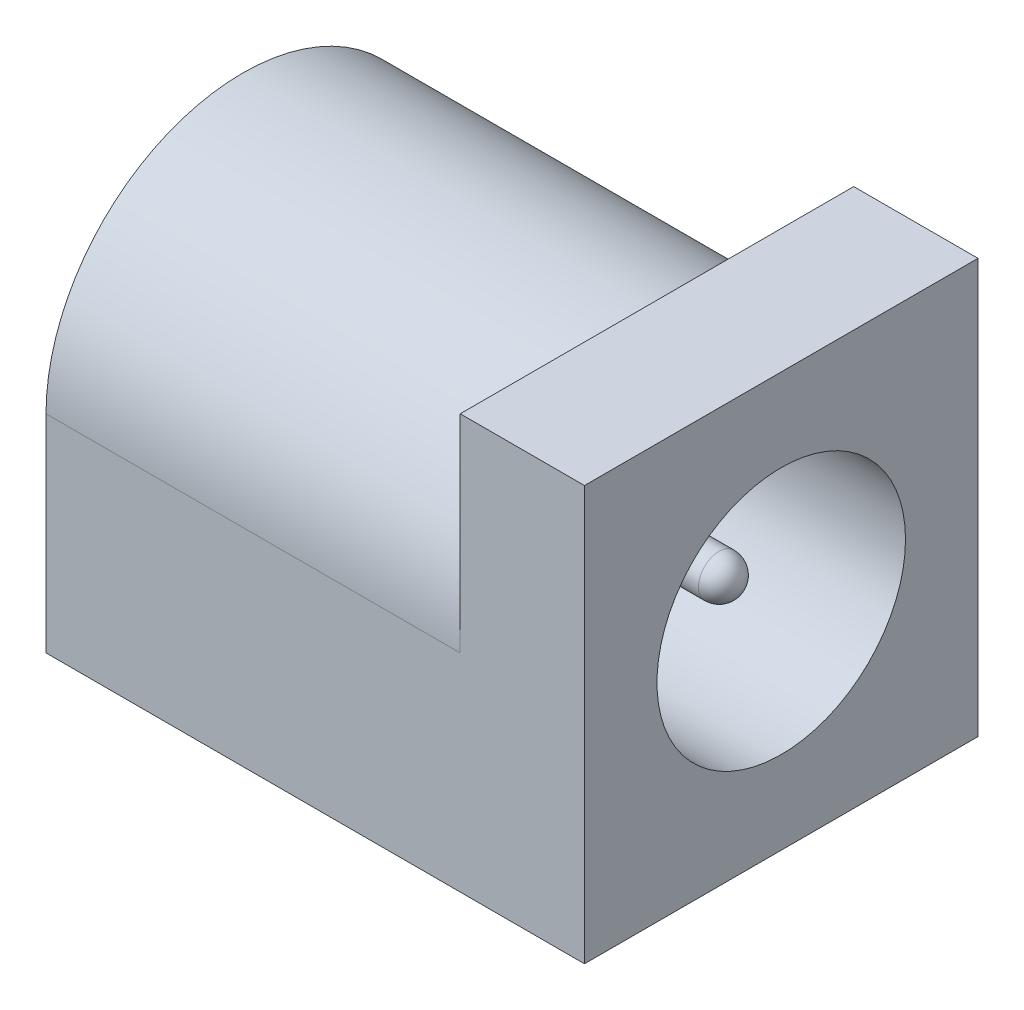
from build123d import *

# Parameters (mm, degrees)
BOSS_EXTRUDE1_DEPTH = 10
SKETCH2_W           = 9.5
SKETCH2_H           = 10
BOSS_EXTRUDE2_DEPTH = 3
SKETCH3_R           = 3
CUT_EXTRUDE1_DEPTH  = 12
SKETCH4_R           = 0.5
BOSS_EXTRUDE3_DEPTH = 11
FILLET1_R           = 0.5


with BuildPart() as part:
    # Sketch1 → Boss-Extrude1 (new body)
    with BuildSketch(Plane(origin=(0, 0, 0), x_dir=(0, 0, -1), z_dir=(1, 0, 0))):
        with BuildLine():
            Line((-4.75, -2.5), (4.75, -2.5))
            Line((4.75, -2.5), (4.75, 2.5))
            ThreePointArc((4.75, 2.5), (0, 7.25), (-4.75, 2.5))
            Line((-4.75, 2.5), (-4.75, -2.5))
        make_face()
    extrude(amount=BOSS_EXTRUDE1_DEPTH)

    # Sketch2 → Boss-Extrude2 (add)
    with BuildSketch(Plane(origin=(10, 0, 0), x_dir=(0, 0, -1), z_dir=(1, 0, 0))):
        with Locations((0, 2.5)):
            Rectangle(SKETCH2_W, SKETCH2_H)
    extrude(amount=BOSS_EXTRUDE2_DEPTH)

    # Sketch3 → Cut-Extrude1 (cut)
    with BuildSketch(Plane(origin=(13, 0, 0), x_dir=(0, 0, -1), z_dir=(1, 0, 0))):
        with Locations((0, 2.5)):
            Circle(SKETCH3_R)
    extrude(amount=-CUT_EXTRUDE1_DEPTH, mode=Mode.SUBTRACT)

    # Sketch4 → Boss-Extrude3 (add)
    with BuildSketch(Plane(origin=(1, 0, 0), x_dir=(0, 0, -1), z_dir=(1, 0, 0))):
        with Locations((0, 2.5)):
            Circle(SKETCH4_R)
    extrude(amount=BOSS_EXTRUDE3_DEPTH)

    # Fillet1
    fillet1_edges = [part.edges().sort_by_distance(p)[0] for p in [
        (12, 2.5, 0.5),
    ]]
    fillet(fillet1_edges, radius=FILLET1_R)


solid = part.part
